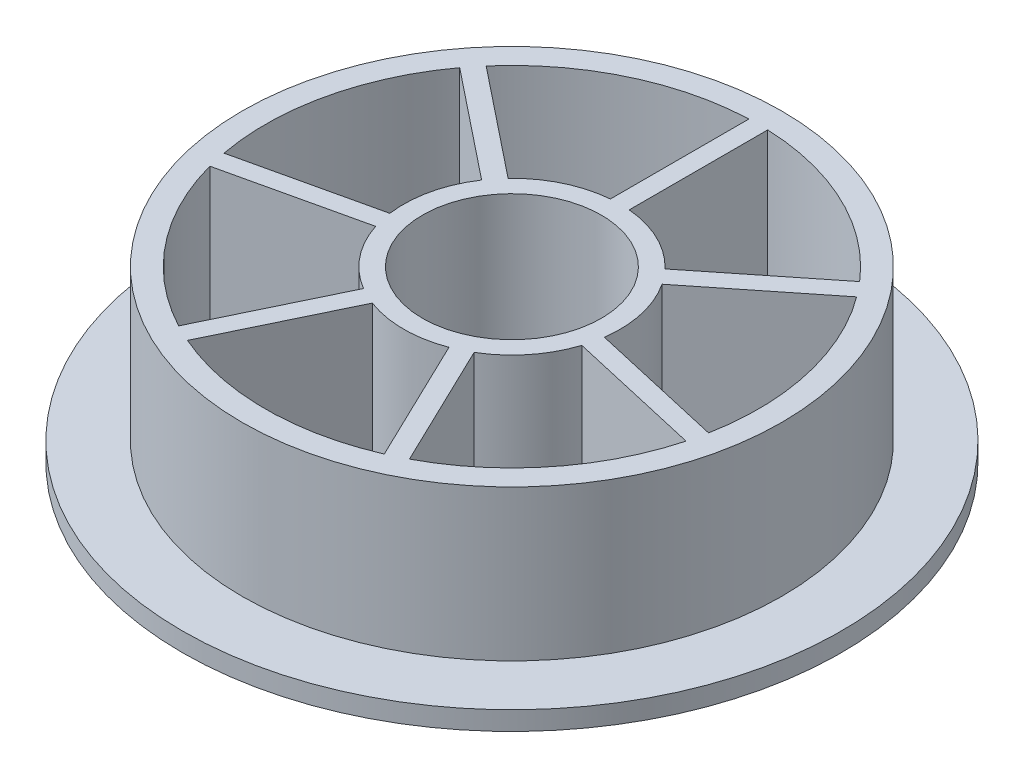
from build123d import *

# Parameters (mm, degrees)
SKETCH_1_R          = 35
SKETCH_1_R_2        = 9.5
EXTRUDE_1_DEPTH     = 18
SKETCH_2_R          = 40.856384021
SKETCH_2_R_2        = 28.650737954
CUT_EXTRUDE_1_DEPTH = 16


with BuildPart() as part:
    # 草图1 → 凸台-拉伸1 (new body)
    with BuildSketch(Plane(origin=(0, 0, 0), x_dir=(1, 0, 0), z_dir=(0, 1, 0))):
        Circle(SKETCH_1_R)
        Circle(SKETCH_1_R_2, mode=Mode.SUBTRACT)
        with BuildLine():
            Line((19.832862473, 17.095228055), (8.333515071, 7.924804513))
            ThreePointArc((8.333515071, 7.924804513), (4.989663, 10.361141981), (1, 11.456439237))
            Line((1, 11.456439237), (1, 26.164656621))
            ThreePointArc((1, 26.164656621), (11.360707431, 23.59075206), (19.832862473, 17.095228055))
        make_face(mode=Mode.SUBTRACT)
        with BuildLine():
            Line((-1, 26.164656621), (-1, 11.456439237))
            ThreePointArc((-1, 11.456439237), (-4.989663, 10.361141981), (-8.333515071, 7.924804513))
            Line((-8.333515071, 7.924804513), (-19.832862473, 17.095228055))
            ThreePointArc((-19.832862473, 17.095228055), (-11.360707431, 23.59075206), (-1, 26.164656621))
        make_face(mode=Mode.SUBTRACT)
        with BuildLine():
            Line((21.079842076, 15.53156509), (9.580494675, 6.361141548))
            ThreePointArc((9.580494675, 6.361141548), (11.21167099, 2.55899074), (11.391723321, -1.574369647))
            Line((11.391723321, -1.574369647), (25.731174987, -4.847255916))
            ThreePointArc((25.731174987, -4.847255916), (25.527277881, 5.826434595), (21.079842076, 15.53156509))
        make_face(mode=Mode.SUBTRACT)
        with BuildLine():
            Line((25.286133119, -6.79711174), (10.946681453, -3.524225471))
            ThreePointArc((10.946681453, -3.524225471), (8.991062048, -7.170132721), (5.871731561, -9.888011351))
            Line((5.871731561, -9.888011351), (12.253387915, -23.139657316))
            ThreePointArc((12.253387915, -23.139657316), (20.471287425, -16.325306958), (25.286133119, -6.79711174))
        make_face(mode=Mode.SUBTRACT)
        with BuildLine():
            Line((10.45145018, -24.007424794), (4.069793825, -10.755778829))
            ThreePointArc((4.069793825, -10.755778829), (0, -11.5), (-4.069793825, -10.755778829))
            Line((-4.069793825, -10.755778829), (-10.45145018, -24.007424794))
            ThreePointArc((-10.45145018, -24.007424794), (0, -26.183759396), (10.45145018, -24.007424794))
        make_face(mode=Mode.SUBTRACT)
        with BuildLine():
            Line((-12.253387915, -23.139657316), (-5.871731561, -9.888011351))
            ThreePointArc((-5.871731561, -9.888011351), (-8.991062048, -7.170132721), (-10.946681453, -3.524225471))
            Line((-10.946681453, -3.524225471), (-25.286133119, -6.79711174))
            ThreePointArc((-25.286133119, -6.79711174), (-20.471287425, -16.325306958), (-12.253387915, -23.139657316))
        make_face(mode=Mode.SUBTRACT)
        with BuildLine():
            Line((-25.731174987, -4.847255916), (-11.391723321, -1.574369647))
            ThreePointArc((-11.391723321, -1.574369647), (-11.21167099, 2.55899074), (-9.580494675, 6.361141548))
            Line((-9.580494675, 6.361141548), (-21.079842076, 15.53156509))
            ThreePointArc((-21.079842076, 15.53156509), (-25.527277881, 5.826434595), (-25.731174987, -4.847255916))
        make_face(mode=Mode.SUBTRACT)
    extrude(amount=EXTRUDE_1_DEPTH)

    # 草图2 → 切除-拉伸1 (cut)
    with BuildSketch(Plane(origin=(0, 18, 0), x_dir=(1, 0, 0), z_dir=(0, 1, 0))):
        Circle(SKETCH_2_R)
        Circle(SKETCH_2_R_2, mode=Mode.SUBTRACT)
    extrude(amount=-CUT_EXTRUDE_1_DEPTH, mode=Mode.SUBTRACT)


solid = part.part
